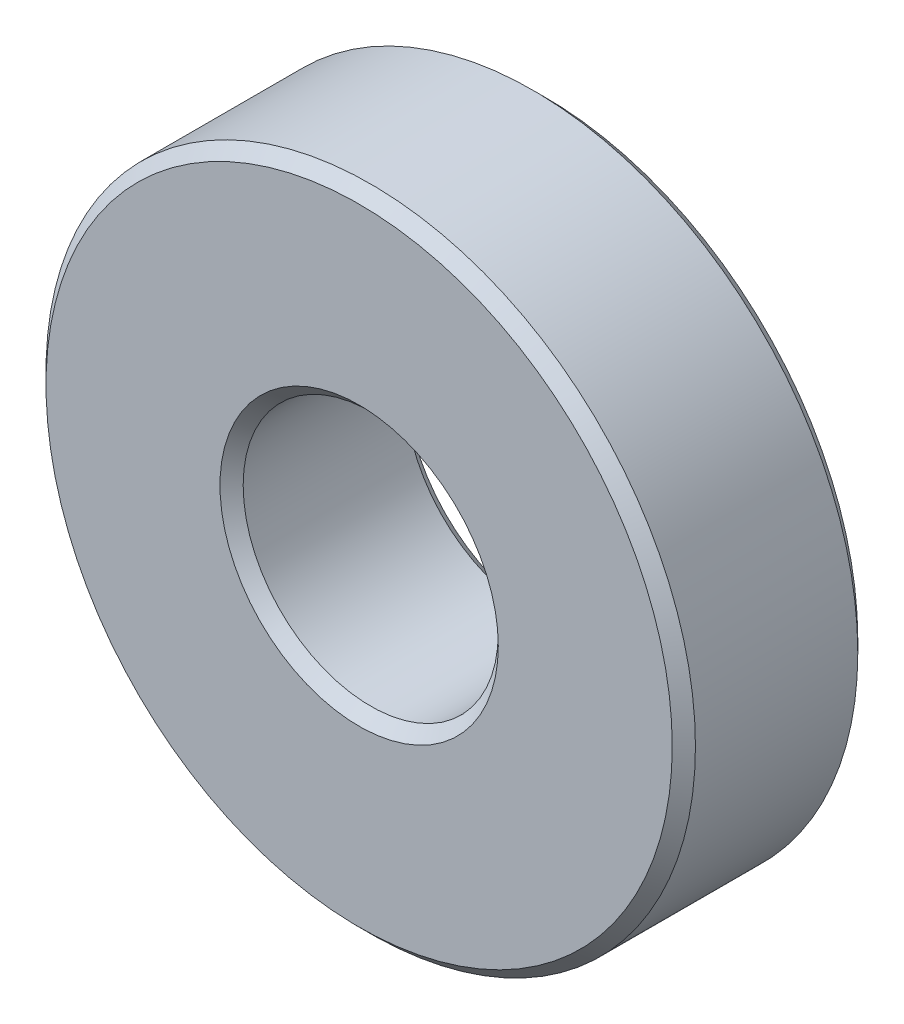
from build123d import *

# Parameters (mm, degrees)
SKETCH1_R           = 14
SKETCH1_R_2         = 5.5
BOSS_EXTRUDE1_DEPTH = 8
CHAMFER1_SIZE       = 0.5


with BuildPart() as part:
    # Sketch1 → Boss-Extrude1 (new body)
    with BuildSketch(Plane.XY):
        Circle(SKETCH1_R)
        Circle(SKETCH1_R_2, mode=Mode.SUBTRACT)
    extrude(amount=BOSS_EXTRUDE1_DEPTH)

    # Chamfer1
    chamfer1_edges = [part.edges().sort_by_distance(p)[0] for p in [
        (-14, 0, 0),
        (-14, 0, 8),
        (-5.5, 0, 0),
        (-5.5, 0, 8),
    ]]
    chamfer(chamfer1_edges, length=CHAMFER1_SIZE)


solid = part.part
